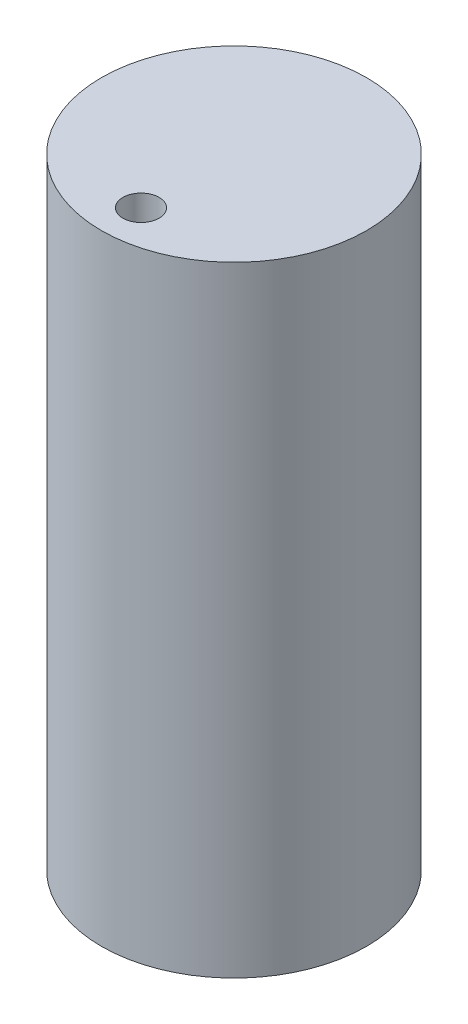
from build123d import *

# Parameters (mm, degrees)
SKETCH1_R           = 10.690012824
SKETCH1_R_2         = 1.457729021
BOSS_EXTRUDE1_DEPTH = 50


with BuildPart() as part:
    # Sketch1 → Boss-Extrude1 (new body)
    with BuildSketch(Plane(origin=(0, 0, 0), x_dir=(1, 0, 0), z_dir=(0, 1, 0))):
        Circle(SKETCH1_R)
        with Locations((0, -7.5)):
            Circle(SKETCH1_R_2, mode=Mode.SUBTRACT)
    extrude(amount=BOSS_EXTRUDE1_DEPTH)


solid = part.part
